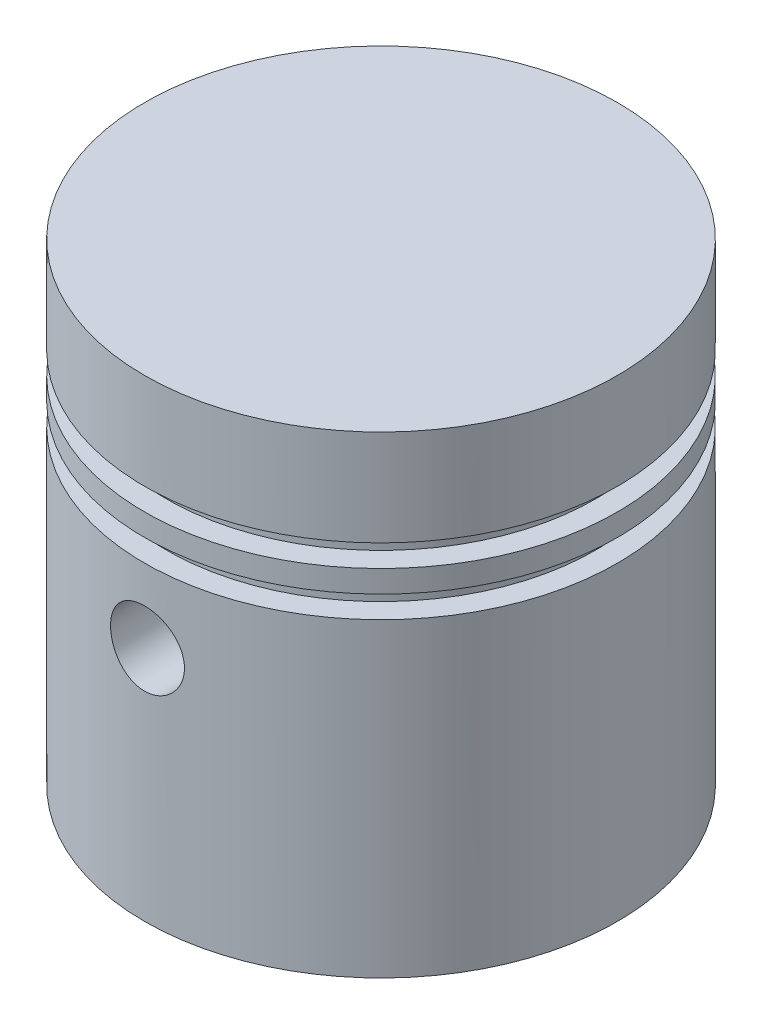
from build123d import *

# Parameters (mm, degrees)
SKETCH1_R               = 8
BOSS_EXTRUDE1_DEPTH     = 16
SKETCH2_R               = 6.5
CUT_EXTRUDE1_DEPTH      = 5
SKETCH3_R               = 5
CUT_EXTRUDE2_DEPTH      = 12
CUT_EXTRUDE3_DEPTH      = 20.595917942
CUT_EXTRUDE3_DEPTH_BACK = 20.595917942
SKETCH4_R               = 1.25
CUT_EXTRUDE5_START      = -10.5
SKETCH5_R               = 8
SKETCH5_R_2             = 7.25
CUT_EXTRUDE5_DEPTH      = 0.75
CUT_EXTRUDE6_START      = -12
SKETCH5_3_R             = 8
SKETCH5_3_R_2           = 7.25
CUT_EXTRUDE6_DEPTH      = 0.75


with BuildPart() as part:
    # Sketch1 → Boss-Extrude1 (new body)
    with BuildSketch(Plane(origin=(0, 0, 0), x_dir=(1, 0, 0), z_dir=(0, 1, 0))):
        Circle(SKETCH1_R)
    extrude(amount=BOSS_EXTRUDE1_DEPTH)

    # Sketch2 → Cut-Extrude1 (cut)
    with BuildSketch(Plane.XZ):
        Circle(SKETCH2_R)
    extrude(amount=-CUT_EXTRUDE1_DEPTH, mode=Mode.SUBTRACT)

    # Sketch3 → Cut-Extrude2 (cut)
    with BuildSketch(Plane.XZ):
        Circle(SKETCH3_R)
    extrude(amount=-CUT_EXTRUDE2_DEPTH, mode=Mode.SUBTRACT)

    # Sketch4 → Cut-Extrude3 (cut, two sides: drawn at the far end of the back side and taken through both)
    with BuildSketch(Plane.XY.offset(-CUT_EXTRUDE3_DEPTH_BACK)):
        with Locations((0, 8)):
            Circle(SKETCH4_R)
    extrude(amount=CUT_EXTRUDE3_DEPTH + CUT_EXTRUDE3_DEPTH_BACK, mode=Mode.SUBTRACT)

    # Sketch5 → Cut-Extrude5 (cut)
    with BuildSketch(Plane.XZ.offset(CUT_EXTRUDE5_START)):
        Circle(SKETCH5_R)
        Circle(SKETCH5_R_2, mode=Mode.SUBTRACT)
    extrude(amount=-CUT_EXTRUDE5_DEPTH, mode=Mode.SUBTRACT)

    # Sketch5_3 → Cut-Extrude6 (cut)
    with BuildSketch(Plane.XZ.offset(CUT_EXTRUDE6_START)):
        Circle(SKETCH5_3_R)
        Circle(SKETCH5_3_R_2, mode=Mode.SUBTRACT)
    extrude(amount=-CUT_EXTRUDE6_DEPTH, mode=Mode.SUBTRACT)


solid = part.part
